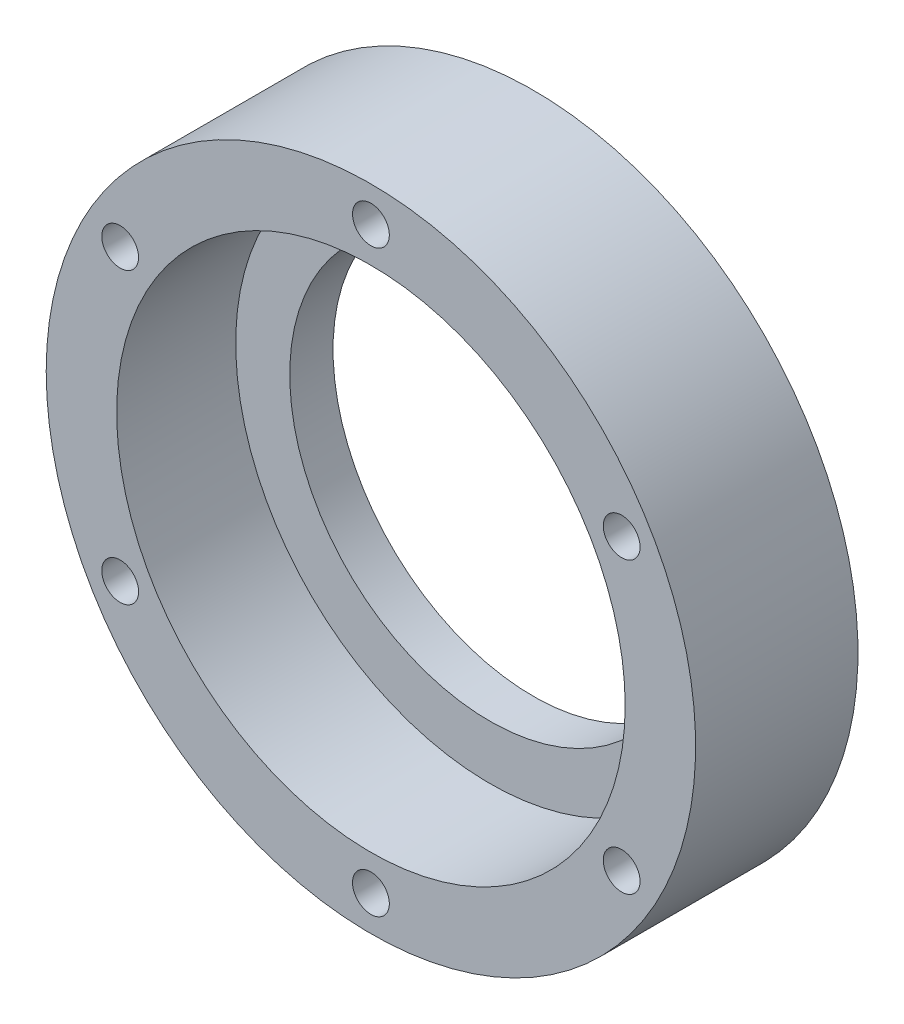
from build123d import *

# Parameters (mm, degrees)
SKETCH1_W                 = 30
SKETCH1_H                 = 15
F_4_CLEARANCE_HOLE1_D     = 3.4
F_4_CLEARANCE_HOLE1_DEPTH = 15
HOLE1_D                   = 37
HOLE1_DEPTH               = 15
HOLE1_CBORE_D             = 46.98238
HOLE1_CBORE_DEPTH         = 11
CHAMFER1_SIZE             = 1.45


with BuildPart() as part:
    # Sketch1 → Revolve1 (revolve)
    with BuildSketch(Plane.XZ):
        with Locations((15, 7.5)):
            Rectangle(SKETCH1_W, SKETCH1_H)
    revolve(axis=Axis((0, 0, 15), (0, 0, -1)))

    # #4 Clearance Hole1
    with Locations(Plane(origin=(0, 0, 0), x_dir=(-1, 0, 0), z_dir=(0, 0, -1))):
        with Locations((-23.166179551, -13.375), (-23.166179551, 13.375), (0, 26.75), (23.166179551, -13.375), (0, -26.75), (23.166179551, 13.375)):
            Hole(F_4_CLEARANCE_HOLE1_D / 2, depth=F_4_CLEARANCE_HOLE1_DEPTH)

    # Hole1
    with Locations(Plane.XY.offset(15)):
        with Locations((0, 0)):
            CounterBoreHole(HOLE1_D / 2, HOLE1_CBORE_D / 2, HOLE1_CBORE_DEPTH, depth=HOLE1_DEPTH)

    # Chamfer1
    chamfer1_edges = [part.edges().sort_by_distance(p)[0] for p in [
        (-24.866179551, 13.375, 0),
        (-1.7, -26.75, 0),
        (-24.866179551, -13.375, 0),
        (-1.7, 26.75, 0),
        (21.466179551, 13.375, 0),
        (21.466179551, -13.375, 0),
    ]]
    chamfer(chamfer1_edges, length=CHAMFER1_SIZE)


solid = part.part
